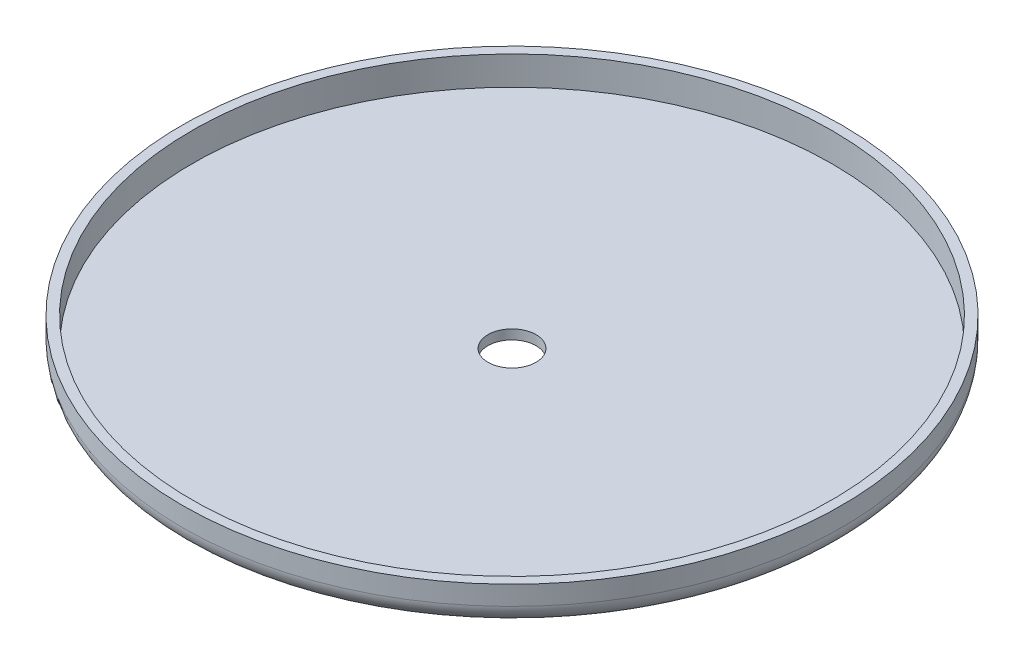
from build123d import *

# Parameters (mm, degrees)
SKETCH1_R           = 42.291
SKETCH1_R_2         = 3.175
BOSS_EXTRUDE1_DEPTH = 1.27
SKETCH2_R           = 43.561
SKETCH2_R_2         = 42.291
BOSS_EXTRUDE2_DEPTH = 5.08
FILLET1_R           = 2.54


with BuildPart() as part:
    # Sketch1 → Boss-Extrude1 (new body)
    with BuildSketch(Plane(origin=(0, 0, 0), x_dir=(1, 0, 0), z_dir=(0, 1, 0))):
        Circle(SKETCH1_R)
        Circle(SKETCH1_R_2, mode=Mode.SUBTRACT)
    extrude(amount=BOSS_EXTRUDE1_DEPTH)

    # Sketch2 → Boss-Extrude2 (add)
    with BuildSketch(Plane.XZ):
        Circle(SKETCH2_R)
        Circle(SKETCH2_R_2, mode=Mode.SUBTRACT)
    extrude(amount=-BOSS_EXTRUDE2_DEPTH)

    # Fillet1
    fillet1_edges = [part.edges().sort_by_distance(p)[0] for p in [
        (-43.561, 0, 0),
    ]]
    fillet(fillet1_edges, radius=FILLET1_R)


solid = part.part
